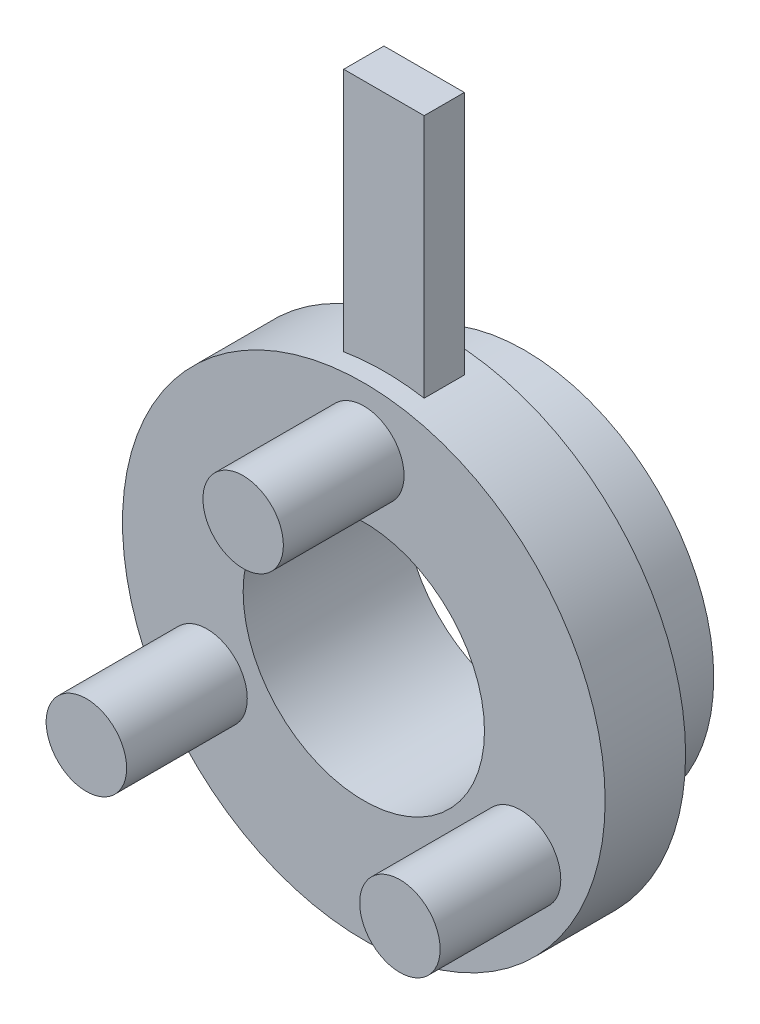
from build123d import *

# Parameters (mm, degrees)
SKETCH1_R                = 23.5
SKETCH1_R_2              = 15
BOSS_EXTRUDE1_DEPTH      = 10
SKETCH2_R                = 30
SKETCH2_R_2              = 15
BOSS_EXTRUDE2_DEPTH      = 10
CHAMFER1_SIZE            = 3
SKETCH3_R                = 5
BOSS_EXTRUDE3_DEPTH      = 15
SKETCH4_W                = 10
SKETCH4_H                = 5
BOSS_EXTRUDE5_DEPTH      = 30
BOSS_EXTRUDE5_DEPTH_BACK = 3


with BuildPart() as part:
    # Sketch1 → Boss-Extrude1 (new body)
    with BuildSketch(Plane.XY):
        Circle(SKETCH1_R)
        Circle(SKETCH1_R_2, mode=Mode.SUBTRACT)
    extrude(amount=-BOSS_EXTRUDE1_DEPTH)

    # Sketch2 → Boss-Extrude2 (add)
    with BuildSketch(Plane.XY):
        Circle(SKETCH2_R)
        Circle(SKETCH2_R_2, mode=Mode.SUBTRACT)
    extrude(amount=BOSS_EXTRUDE2_DEPTH)

    # Chamfer1
    chamfer1_edges = [part.edges().sort_by_distance(p)[0] for p in [
        (-23.5, 0, 0),
    ]]
    chamfer(chamfer1_edges, length=CHAMFER1_SIZE)

    # Sketch3 → Boss-Extrude3 (add)
    with BuildSketch(Plane.XY.offset(10)):
        with Locations((0, 22.5)):
            Circle(SKETCH3_R)
        with Locations((19.485571585, -11.25)):
            Circle(SKETCH3_R)
        with Locations((-19.485571585, -11.25)):
            Circle(SKETCH3_R)
    extrude(amount=BOSS_EXTRUDE3_DEPTH)

    # Sketch4 → Boss-Extrude5 (add, two sides)
    with BuildSketch(Plane(origin=(0, 30, 0), x_dir=(1, 0, 0), z_dir=(0, 1, 0))) as boss_extrude5_sk:
        with Locations((0, -5)):
            Rectangle(SKETCH4_W, SKETCH4_H)
    extrude(amount=BOSS_EXTRUDE5_DEPTH)
    extrude(boss_extrude5_sk.sketch, amount=-BOSS_EXTRUDE5_DEPTH_BACK)


solid = part.part
